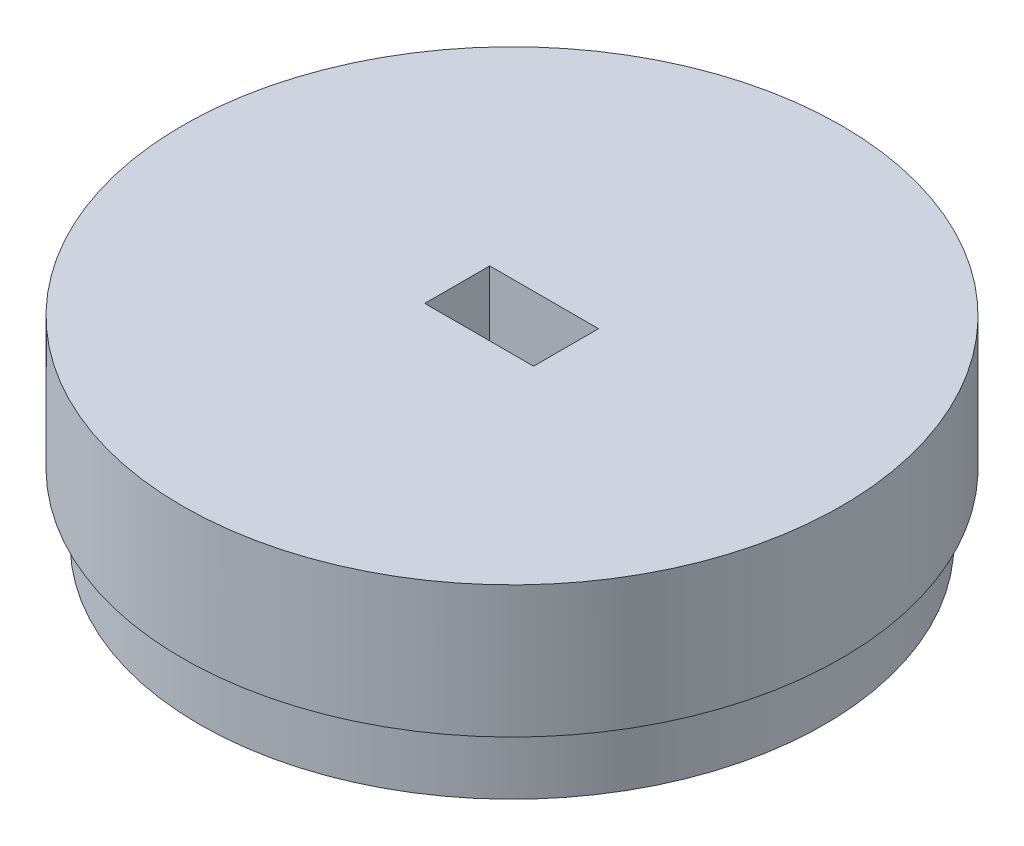
from build123d import *

# Parameters (mm, degrees)
SKETCH1_R           = 15
BOSS_EXTRUDE1_DEPTH = 9
SKETCH6_OUTSIDE_W   = 40.674
SKETCH6_OUTSIDE_H   = 40.674
SKETCH6_OUTSIDE_R   = 14.222015383
CUT_EXTRUDE4_DEPTH  = 3
SKETCH8_W           = 4.952506836
SKETCH8_H           = 2.956951794
CUT_EXTRUDE5_DEPTH  = 6


with BuildPart() as part:
    # Sketch1 → Boss-Extrude1 (new body)
    with BuildSketch(Plane(origin=(0, 0, 0), x_dir=(1, 0, 0), z_dir=(0, 1, 0))):
        Circle(SKETCH1_R)
    extrude(amount=BOSS_EXTRUDE1_DEPTH)

    # Sketch6 outside → Cut-Extrude4 (cut)
    with BuildSketch(Plane.XZ):
        Rectangle(SKETCH6_OUTSIDE_W, SKETCH6_OUTSIDE_H)
        Circle(SKETCH6_OUTSIDE_R, mode=Mode.SUBTRACT)
    extrude(amount=-CUT_EXTRUDE4_DEPTH, mode=Mode.SUBTRACT)

    # Sketch8 → Cut-Extrude5 (cut)
    with BuildSketch(Plane(origin=(0, 9, 0), x_dir=(1, 0, 0), z_dir=(0, 1, 0))):
        with Locations((0, -0.017356659)):
            Rectangle(SKETCH8_W, SKETCH8_H)
    extrude(amount=-CUT_EXTRUDE5_DEPTH, mode=Mode.SUBTRACT)


solid = part.part
